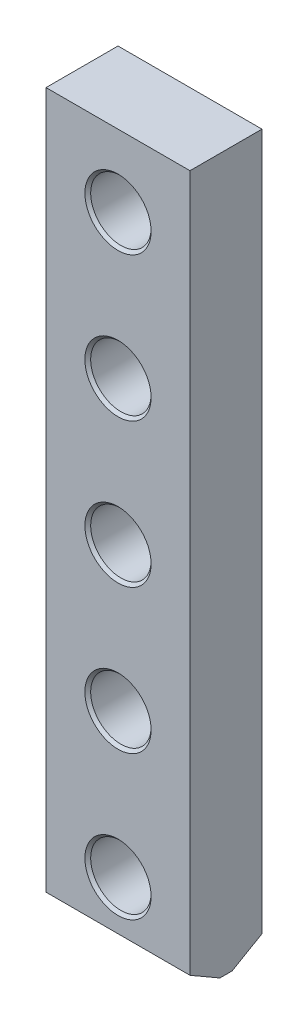
from build123d import *

# Parameters (mm, degrees)
SKETCH_1_W          = 50
SKETCH_1_H          = 248
EXTRUDE_1_DEPTH     = 25
SKETCH_2_R          = 10.5
CUT_EXTRUDE_1_DEPTH = 26
CHAMFER_1_SIZE      = 6
CHAMFER_1_SIZE2     = 10.392304845
CHAMFER_2_SIZE      = 6
CHAMFER_2_SIZE2     = 10.392304845
CHAMFER_3_SIZE      = 1


with BuildPart() as part:
    # Эскиз1 → Бобышка-Вытянуть1 (new body)
    with BuildSketch(Plane.XY):
        with Locations((25, 124)):
            Rectangle(SKETCH_1_W, SKETCH_1_H)
    extrude(amount=EXTRUDE_1_DEPTH)

    # Эскиз2 → Вырез-Вытянуть1 (cut, through all)
    with BuildSketch(Plane.XY.offset(25)):
        with Locations((25, 23)):
            Circle(SKETCH_2_R)
        with Locations((25, 73)):
            Circle(SKETCH_2_R)
        with Locations((25, 123)):
            Circle(SKETCH_2_R)
        with Locations((25, 173)):
            Circle(SKETCH_2_R)
        with Locations((25, 223)):
            Circle(SKETCH_2_R)
    extrude(amount=-CUT_EXTRUDE_1_DEPTH, mode=Mode.SUBTRACT)

    # Фаска1
    chamfer_1_edges = [part.edges().sort_by_distance(p)[0] for p in [
        (25, 0, 0),
    ]]
    chamfer_1_side = [part.faces().sort_by_distance(p)[0] for p in [
        (25, 2.529901184, 0),
    ]]
    chamfer(chamfer_1_edges, length=CHAMFER_1_SIZE, length2=CHAMFER_1_SIZE2, reference=chamfer_1_side[0])

    # Фаска2
    chamfer_2_edges = [part.edges().sort_by_distance(p)[0] for p in [
        (25, 0, 25),
    ]]
    chamfer_2_side = [part.faces().sort_by_distance(p)[0] for p in [
        (25, 2.529901184, 25),
    ]]
    chamfer(chamfer_2_edges, length=CHAMFER_2_SIZE, length2=CHAMFER_2_SIZE2, reference=chamfer_2_side[0])

    # Фаска3
    chamfer_3_edges = [part.edges().sort_by_distance(p)[0] for p in [
        (14.5, 23, 0),
        (14.5, 23, 25),
        (14.5, 73, 0),
        (14.5, 73, 25),
        (14.5, 123, 0),
        (14.5, 123, 25),
        (14.5, 173, 0),
        (14.5, 173, 25),
        (14.5, 223, 0),
        (14.5, 223, 25),
    ]]
    chamfer(chamfer_3_edges, length=CHAMFER_3_SIZE)


solid = part.part
